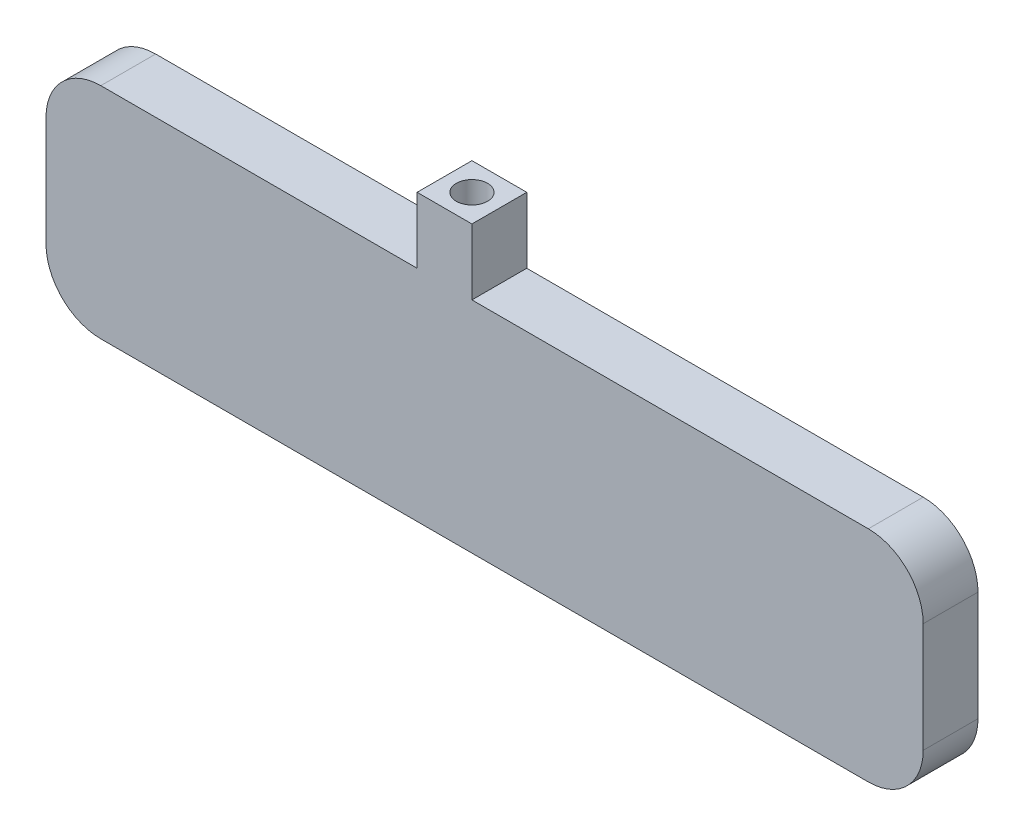
from build123d import *

# Parameters (mm, degrees)
SKETCH1_W           = 80
SKETCH1_H           = 20
BOSS_EXTRUDE1_DEPTH = 5
FILLET1_R           = 5
SHELL1_T            = -2
SKETCH2_W           = 5
SKETCH2_H           = 5
BOSS_EXTRUDE2_DEPTH = 6
SKETCH3_R           = 1.425
CUT_EXTRUDE1_DEPTH  = 4


with BuildPart() as part:
    # Sketch1 → Boss-Extrude1 (new body)
    with BuildSketch(Plane.XY):
        Rectangle(SKETCH1_W, SKETCH1_H)
    extrude(amount=BOSS_EXTRUDE1_DEPTH)

    # Fillet1
    fillet1_edges = [part.edges().sort_by_distance(p)[0] for p in [
        (40, -10, 2.5),
        (-40, -10, 2.5),
        (-40, 10, 2.5),
        (40, 10, 2.5),
    ]]
    fillet(fillet1_edges, radius=FILLET1_R)

    # Shell1
    shell1_openings = [part.faces().sort_by_distance(p)[0] for p in [
        (0, 0, 0),
    ]]
    offset(amount=SHELL1_T, openings=shell1_openings, kind=Kind.INTERSECTION)

    # Sketch2 → Boss-Extrude2 (add)
    with BuildSketch(Plane(origin=(0, 10, 0), x_dir=(1, 0, 0), z_dir=(0, 1, 0))):
        with Locations((-3.653953893, -2.5)):
            Rectangle(SKETCH2_W, SKETCH2_H)
    extrude(amount=BOSS_EXTRUDE2_DEPTH)

    # Sketch3 → Cut-Extrude1 (cut)
    with BuildSketch(Plane(origin=(0, 16, 0), x_dir=(1, 0, 0), z_dir=(0, 1, 0))):
        with Locations((-3.653953893, -2.5)):
            Circle(SKETCH3_R)
    extrude(amount=-CUT_EXTRUDE1_DEPTH, mode=Mode.SUBTRACT)


solid = part.part
